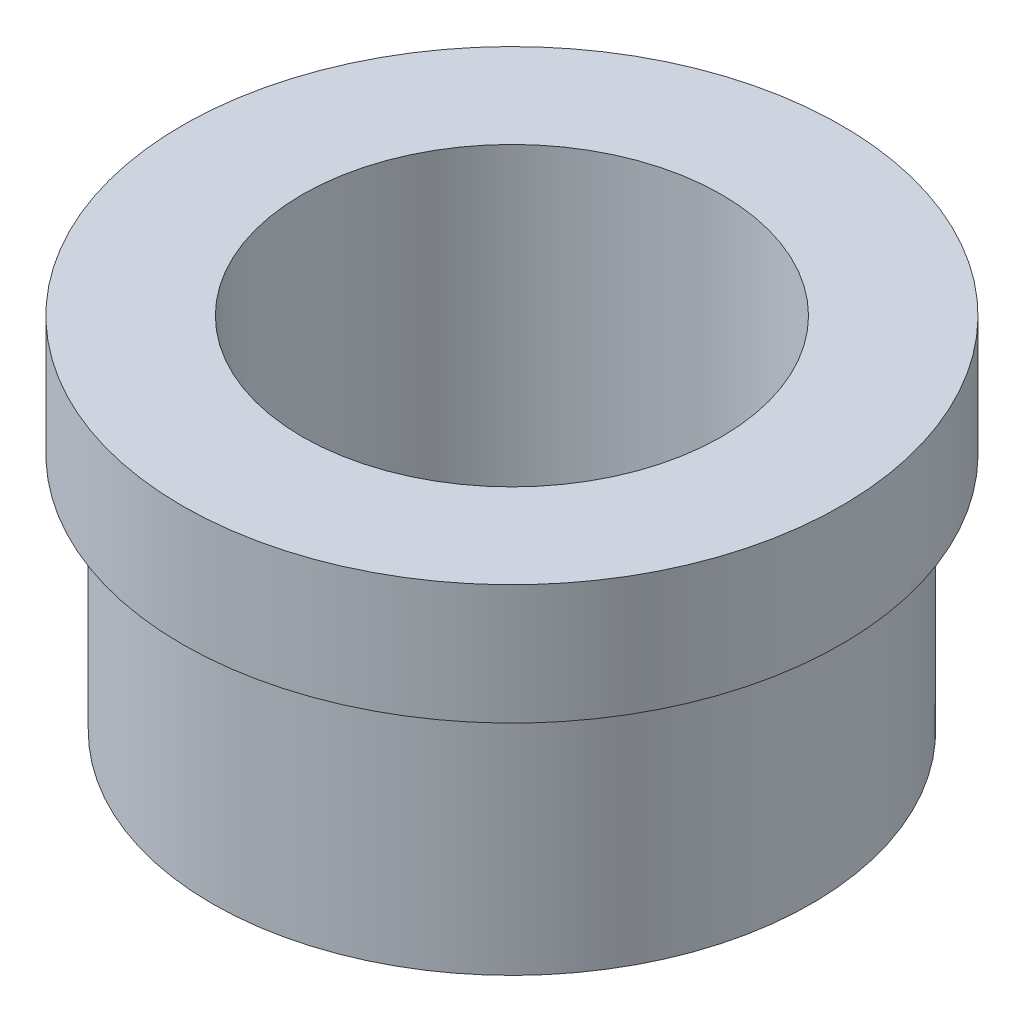
from build123d import *

# Parameters (mm, degrees)
SKETCH1_R           = 25
SKETCH1_R_2         = 17.5
BOSS_EXTRUDE1_DEPTH = 20
SKETCH2_R           = 27.5
SKETCH2_R_2         = 17.5
BOSS_EXTRUDE2_DEPTH = 10


with BuildPart() as part:
    # Sketch1 → Boss-Extrude1 (new body)
    with BuildSketch(Plane(origin=(0, 0, 0), x_dir=(1, 0, 0), z_dir=(0, 1, 0))):
        Circle(SKETCH1_R)
        Circle(SKETCH1_R_2, mode=Mode.SUBTRACT)
    extrude(amount=BOSS_EXTRUDE1_DEPTH)

    # Sketch2 → Boss-Extrude2 (add)
    with BuildSketch(Plane(origin=(0, 20, 0), x_dir=(1, 0, 0), z_dir=(0, 1, 0))):
        Circle(SKETCH2_R)
        Circle(SKETCH2_R_2, mode=Mode.SUBTRACT)
    extrude(amount=BOSS_EXTRUDE2_DEPTH)


solid = part.part
